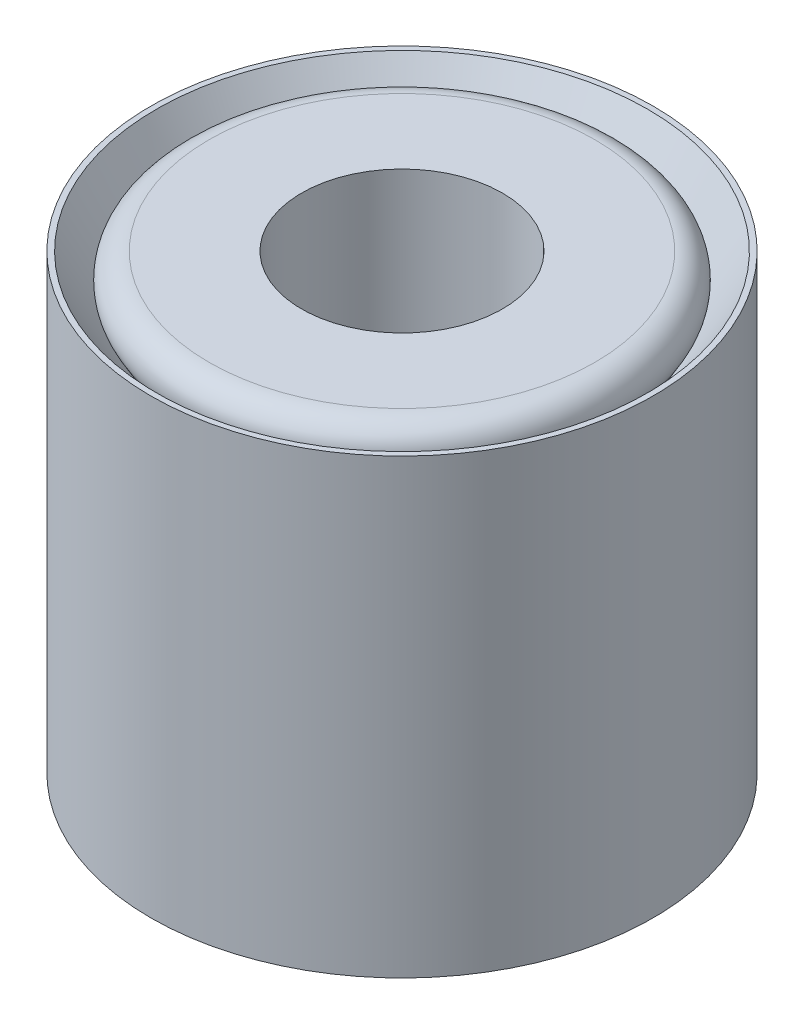
from build123d import *

# Parameters (mm, degrees)
FILLET1_R = 1
FILLET8_R = 0.5


with BuildPart() as part:
    # Sketch1 → Revolve1 (revolve)
    with BuildSketch(Plane.XY):
        Polygon((5, -4.5), (4.891414149, -4.5), (2.293337937, 0), (4.891414149, 4.5), (5, 4.5), align=None)
        Polygon((2, -4.5), (2, 4.5), (4.706662063, 4.5), (2.108585851, 0), (4.706662063, -4.5), align=None)
    revolve(axis=Axis((0, -4.5, 0), (0, 1, 0)))

    # Fillet1
    fillet1_edges = [part.edges().sort_by_distance(p)[0] for p in [
        (-2.293337937, 0, 0),
    ]]
    fillet(fillet1_edges, radius=FILLET1_R)

    # Fillet8
    fillet8_edges = [part.edges().sort_by_distance(p)[0] for p in [
        (-2, -4.5, 0),
        (-4.706662063, -4.5, 0),
        (-4.706662063, 4.5, 0),
    ]]
    fillet(fillet8_edges, radius=FILLET8_R)


solid = part.part
